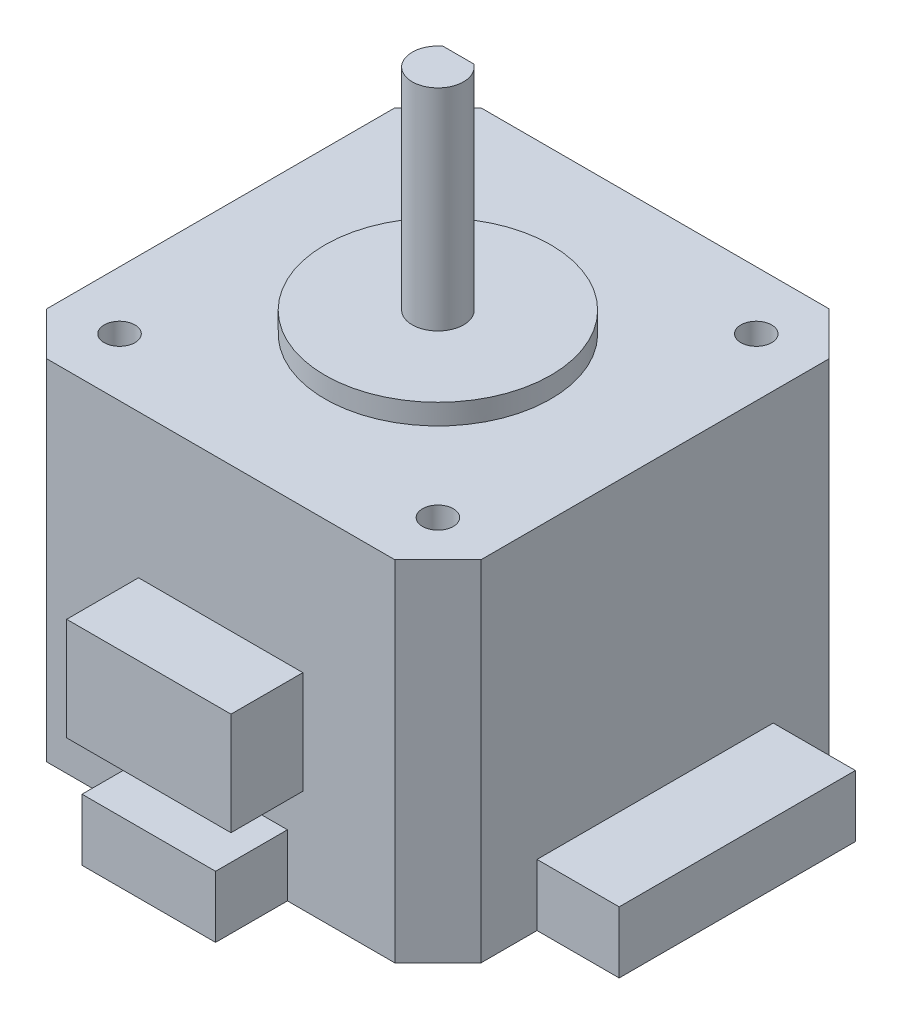
from build123d import *

# Parameters (mm, degrees)
SKETCH_1_W          = 42.3
SKETCH_1_H          = 42.3
EXTRUDE_1_DEPTH     = 34
CHAMFER_1_SIZE      = 4.2
SKETCH_2_R          = 1.5
CUT_EXTRUDE_1_DEPTH = 4.5
SKETCH_3_R          = 11
EXTRUDE_2_DEPTH     = 2
SKETCH_4_R          = 2.5
EXTRUDE_3_DEPTH     = 20.5
CUT_EXTRUDE_2_DEPTH = 18
SKETCH_6_W          = 16
SKETCH_6_H          = 10
SKETCH_6_W_2        = 13
SKETCH_6_H_2        = 6
EXTRUDE_4_DEPTH     = 7
SKETCH_7_W          = 23
SKETCH_7_H          = 6
EXTRUDE_5_DEPTH     = 8


with BuildPart() as part:
    # 草图1 → 凸台-拉伸1 (new body)
    with BuildSketch(Plane(origin=(0, 0, 0), x_dir=(1, 0, 0), z_dir=(0, 1, 0))):
        with Locations((21.15, 21.15)):
            Rectangle(SKETCH_1_W, SKETCH_1_H)
    extrude(amount=EXTRUDE_1_DEPTH)

    # 倒角1
    chamfer_1_edges = [part.edges().sort_by_distance(p)[0] for p in [
        (0, 17, -42.3),
        (42.3, 17, -42.3),
        (42.3, 17, 0),
        (0, 17, 0),
    ]]
    chamfer(chamfer_1_edges, length=CHAMFER_1_SIZE)

    # 草图2 → 切除-拉伸1 (cut)
    with BuildSketch(Plane(origin=(0, 34, 0), x_dir=(1, 0, 0), z_dir=(0, 1, 0))):
        with Locations((5.65, 36.65)):
            Circle(SKETCH_2_R)
        with Locations((36.65, 36.65)):
            Circle(SKETCH_2_R)
        with Locations((5.65, 5.65)):
            Circle(SKETCH_2_R)
        with Locations((36.65, 5.65)):
            Circle(SKETCH_2_R)
    extrude(amount=-CUT_EXTRUDE_1_DEPTH, mode=Mode.SUBTRACT)

    # 草图3 → 凸台-拉伸2 (add)
    with BuildSketch(Plane(origin=(0, 34, 0), x_dir=(1, 0, 0), z_dir=(0, 1, 0))):
        with Locations((21.15, 21.15)):
            Circle(SKETCH_3_R)
    extrude(amount=EXTRUDE_2_DEPTH)

    # 草图4 → 凸台-拉伸3 (add)
    with BuildSketch(Plane(origin=(0, 36, 0), x_dir=(1, 0, 0), z_dir=(0, 1, 0))):
        with Locations((21.15, 21.15)):
            Circle(SKETCH_4_R)
    extrude(amount=EXTRUDE_3_DEPTH)

    # 草图5 → 切除-拉伸2 (cut)
    with BuildSketch(Plane(origin=(0, 56.5, 0), x_dir=(1, 0, 0), z_dir=(0, 1, 0))):
        with BuildLine():
            Line((19.65, 23.15), (22.65, 23.15))
            ThreePointArc((22.65, 23.15), (21.15, 23.65), (19.65, 23.15))
        make_face()
    extrude(amount=-CUT_EXTRUDE_2_DEPTH, mode=Mode.SUBTRACT)

    # 草图6 → 凸台-拉伸4 (add)
    with BuildSketch(Plane.XY):
        with Locations((21.15, 15)):
            Rectangle(SKETCH_6_W, SKETCH_6_H)
        with Locations((21.15, 3)):
            Rectangle(SKETCH_6_W_2, SKETCH_6_H_2)
    extrude(amount=EXTRUDE_4_DEPTH)

    # 草图7 → 凸台-拉伸5 (add)
    with BuildSketch(Plane(origin=(42.3, 0, 0), x_dir=(0, 0, -1), z_dir=(1, 0, 0))):
        with Locations((21.15, 3)):
            Rectangle(SKETCH_7_W, SKETCH_7_H)
    extrude(amount=EXTRUDE_5_DEPTH)


solid = part.part
